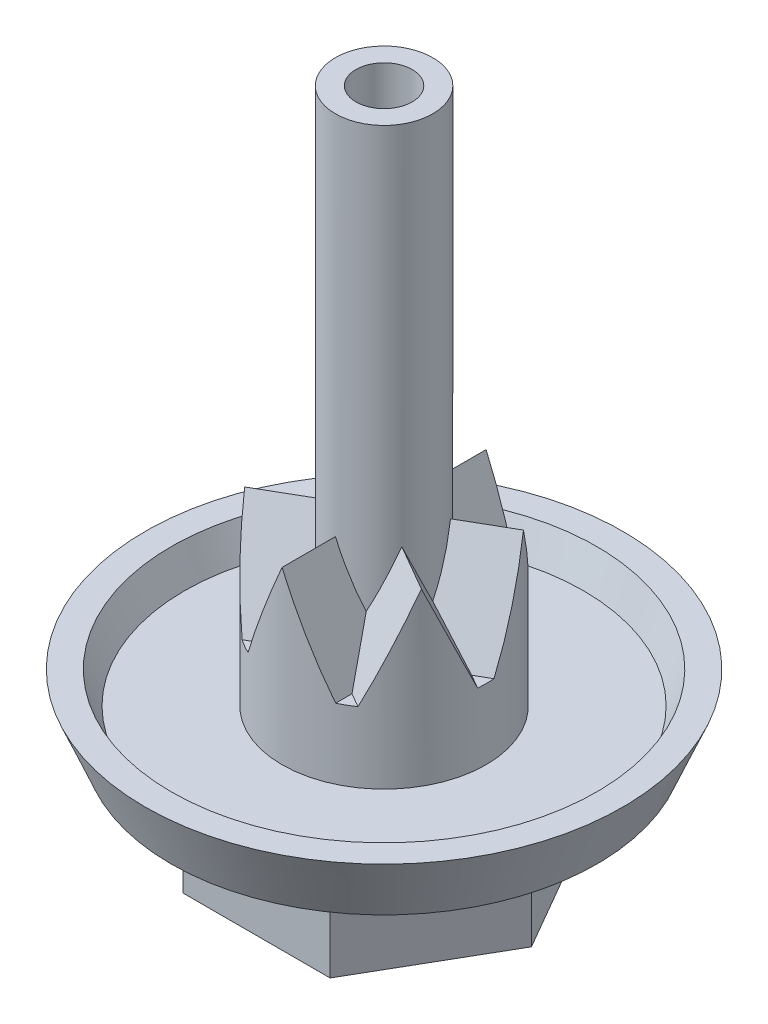
from build123d import *

# Parameters (mm, degrees)
BOSS_EXTRUDE1_DEPTH      = 5.07
SKETCH2_R                = 11.585
BOSS_EXTRUDE2_DEPTH      = 3.02
CUT_EXTRUDE3_DEPTH       = 5.28
SKETCH12_R               = 4.775
CUT_EXTRUDE4_DEPTH       = 8.48
SKETCH14_R               = 2.36
BOSS_EXTRUDE5_DEPTH      = 24.51
SKETCH15_R               = 4.95
BOSS_EXTRUDE6_DEPTH      = 1.87
BOSS_EXTRUDE7_REACH      = 38.485
BOSS_EXTRUDE7_END_RADIUS = 4.95
CIRPATTERN2_COUNT        = 6
SKETCH17_R               = 1.363462741
CUT_EXTRUDE6_DEPTH       = 22.64


with BuildPart() as part:
    # Sketch1 → Boss-Extrude1 (new body)
    with BuildSketch(Plane(origin=(0, 0, 0), x_dir=(1, 0, 0), z_dir=(0, 1, 0))):
        Polygon((-3.573798166, 6.19), (-7.147596333, 0), (-3.573798166, -6.19), (3.573798166, -6.19), (7.147596333, 0), (3.573798166, 6.19), align=None)
    extrude(amount=BOSS_EXTRUDE1_DEPTH)

    # Sketch2 → Boss-Extrude2 (add)
    with BuildSketch(Plane(origin=(0, 5.07, 0), x_dir=(1, 0, 0), z_dir=(0, 1, 0))):
        with Locations(Location((0, 0, 0), (0, 0, 90))):
            Circle(SKETCH2_R)
    extrude(amount=BOSS_EXTRUDE2_DEPTH)

    # Sketch3 → Cut-Revolve1 (revolve, cut)
    with BuildSketch(Plane.XY, mode=Mode.PRIVATE) as cut_revolve1_sk:
        Polygon((10.33, 5.07), (11.585, 5.07), (11.585, 8.09), align=None)
    revolve(cut_revolve1_sk.sketch.rotate(Axis((0, 10.492775936, 0), (0, -1, 0)), 90), axis=Axis((0, 10.492775936, 0), (0, -1, 0)), mode=Mode.SUBTRACT)

    # Sketch5 → Cut-Revolve2 (revolve, cut)
    with BuildSketch(Plane.XY, mode=Mode.PRIVATE) as cut_revolve2_sk:
        Polygon((10.315, 8.09), (9.675033113, 6.55), (4.95, 6.55), (4.95, 8.27346303), (10.315, 8.27346303), align=None)
    revolve(cut_revolve2_sk.sketch.rotate(Axis((0, 10.346459419, 0), (0, -1, 0)), 90), axis=Axis((0, 10.346459419, 0), (0, -1, 0)), mode=Mode.SUBTRACT)

    # Sketch11 → Cut-Extrude3 (cut)
    with BuildSketch(Plane.XZ):
        Polygon((-2.756847535, 4.775), (-5.513695071, 0), (-2.756847535, -4.775), (2.756847535, -4.775), (5.513695071, 0), (2.756847535, 4.775), align=None)
    extrude(amount=-CUT_EXTRUDE3_DEPTH, mode=Mode.SUBTRACT)

    # Sketch12 → Cut-Extrude4 (cut)
    with BuildSketch(Plane.XZ):
        with Locations(Location((0, 0, 0), (0, 0, 90))):
            Circle(SKETCH12_R)
    extrude(amount=-CUT_EXTRUDE4_DEPTH, mode=Mode.SUBTRACT)



with BuildPart() as body_2:
    # Sketch14 → Boss-Extrude5 (new body)
    with BuildSketch(Plane(origin=(0, 8.09, 0), x_dir=(1, 0, 0), z_dir=(0, 1, 0))):
        with Locations(Location((0, 0, 0), (0, 0, 270))):
            Circle(SKETCH14_R)
    extrude(amount=BOSS_EXTRUDE5_DEPTH)


with BuildPart() as part_1:
    add(part.part)

    add(body_2.part)  # Boss-Extrude6 merges body 2
    # Sketch15 → Boss-Extrude6 (add)
    with BuildSketch(Plane(origin=(0, 8.09, 0), x_dir=(1, 0, 0), z_dir=(0, 1, 0))):
        with Locations(Location((0, 0, 0), (0, 0, 270))):
            Circle(SKETCH15_R)
    extrude(amount=BOSS_EXTRUDE6_DEPTH)

    # Boss-Extrude7: up to this cylinder (the profile starts inside it)
    boss_extrude7_end = Plane(origin=(0, 11.586667, 0), z_dir=(0, 1, 0)) * Cylinder(BOSS_EXTRUDE7_END_RADIUS, 87.87, mode=Mode.PRIVATE)
    # Sketch16 → Boss-Extrude7 (add, up to the surface)
    with BuildSketch(Plane.XY, mode=Mode.PRIVATE) as boss_extrude7_sk1:
        Polygon((0, 14.84), (-2.125, 9.96), (2.125, 9.96), align=None)
    boss_extrude7_tool1 = extrude(boss_extrude7_sk1.sketch, amount=BOSS_EXTRUDE7_REACH, mode=Mode.PRIVATE) & boss_extrude7_end
    boss_extrude7 = boss_extrude7_tool1.solids().sort_by_distance((0, 11.586667, 0))[0]
    add(boss_extrude7)

    # CirPattern2: Boss-Extrude7 ×6 about axis
    cirpattern2_axis = Axis((0, 0, 0), (0, 1, 0))
    for i in range(1, CIRPATTERN2_COUNT):
        add(boss_extrude7.rotate(cirpattern2_axis, i * 360 / CIRPATTERN2_COUNT))

    # Sketch17 → Cut-Extrude6 (cut)
    with BuildSketch(Plane(origin=(0, 32.6, 0), x_dir=(1, 0, 0), z_dir=(0, 1, 0))):
        with Locations(Location((0, 0, 0), (0, 0, 270))):
            Circle(SKETCH17_R)
    extrude(amount=-CUT_EXTRUDE6_DEPTH, mode=Mode.SUBTRACT)


solid = part_1.part
